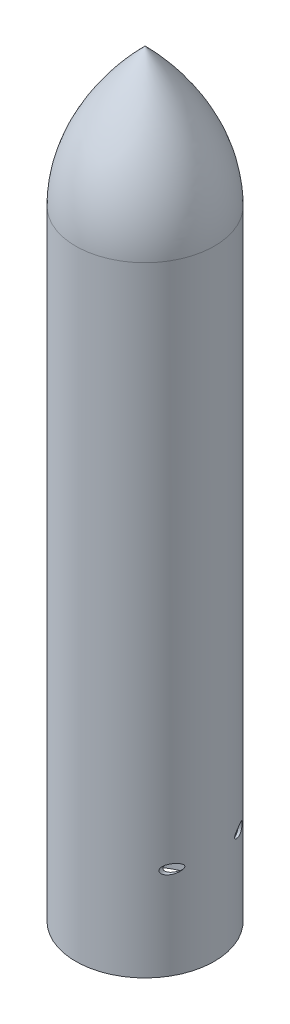
from build123d import *

# Parameters (mm, degrees)
SKETCH2_R          = 10
CUT_EXTRUDE1_DEPTH = 151.0000001


with BuildPart() as part:
    # Sketch1 → Revolve1 (revolve)
    with BuildSketch(Plane.XY):
        with BuildLine():
            Line((-150, 0), (-150, 1340))
            add(Edge.make_bspline(
                [(0, 1640), (-150, 1490), (-150, 1340)],
                knots=[0, 0, 0, 1, 1, 1], degree=2))
            Line((0, 1640), (0, 1632.952723956))
            Line((0, 1632.952723956), (-5, 1627.803149448))
            add(Edge.make_bspline(
                [(-5, 1627.803149448), (-57.694245938, 1573.511585517), (-112.347233502, 1483.42653426), (-145.016403602, 1393.670587787), (-145, 1340)],
                knots=[0.029045994, 0.029045994, 0.029045994, 0.393153746, 0.635892248, 1, 1, 1], degree=2))
            Line((-145, 1340), (-145, 5))
            Line((-145, 5), (-145, 0))
            Line((-145, 0), (-150, 0))
        make_face()
    revolve(axis=Axis((0, 0, 0), (0, 1, 0)))

    # Sketch2 → Cut-Extrude1 (cut, symmetric)
    with BuildSketch(Plane.XY):
        with Locations((130, 200)):
            Circle(SKETCH2_R)
    cut_extrude1 = extrude(amount=CUT_EXTRUDE1_DEPTH, both=True, mode=Mode.SUBTRACT)

    # Mirror1: Cut-Extrude1 across plane
    add(cut_extrude1.mirror(Plane(origin=(0, 0, 0), x_dir=(0, 0, 1), z_dir=(1, 0, 0))), mode=Mode.SUBTRACT)


solid = part.part
